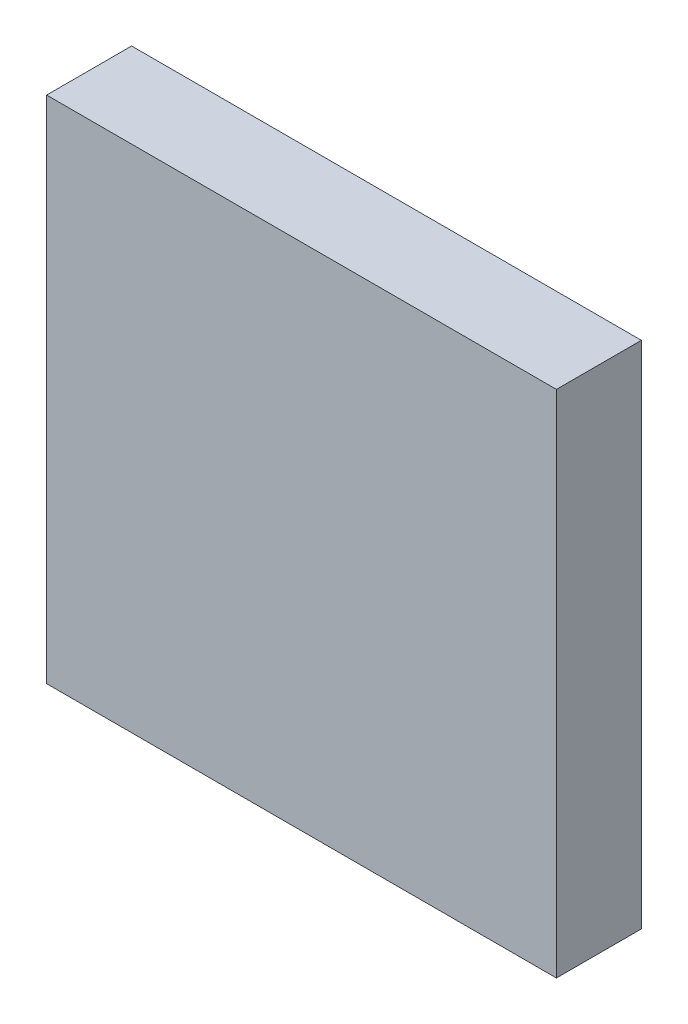
from build123d import *

# Parameters (mm, degrees)
CROQUIS1_W              = 60
CROQUIS1_H              = 60
SALIENTE_EXTRUIR1_DEPTH = 10


with BuildPart() as part:
    # Croquis1 → Saliente-Extruir1 (new body)
    with BuildSketch(Plane.XY):
        Rectangle(CROQUIS1_W, CROQUIS1_H)
    extrude(amount=SALIENTE_EXTRUIR1_DEPTH)


solid = part.part
